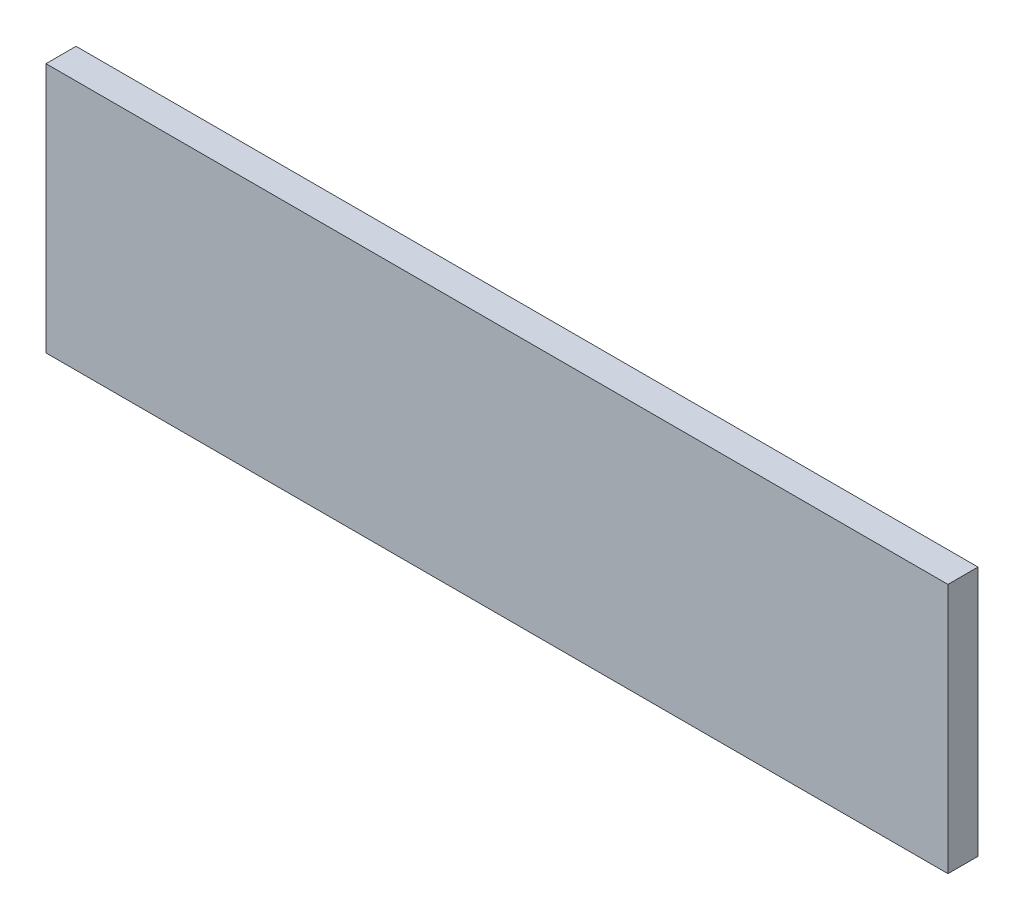
from build123d import *

# Parameters (mm, degrees)
ESQUISSE1_W        = 90
ESQUISSE1_H        = 25
BOSS_EXTRU_1_DEPTH = 3


with BuildPart() as part:
    # Esquisse1 → Boss.-Extru.1 (new body)
    with BuildSketch(Plane.XY):
        Rectangle(ESQUISSE1_W, ESQUISSE1_H)
    extrude(amount=BOSS_EXTRU_1_DEPTH)


solid = part.part
